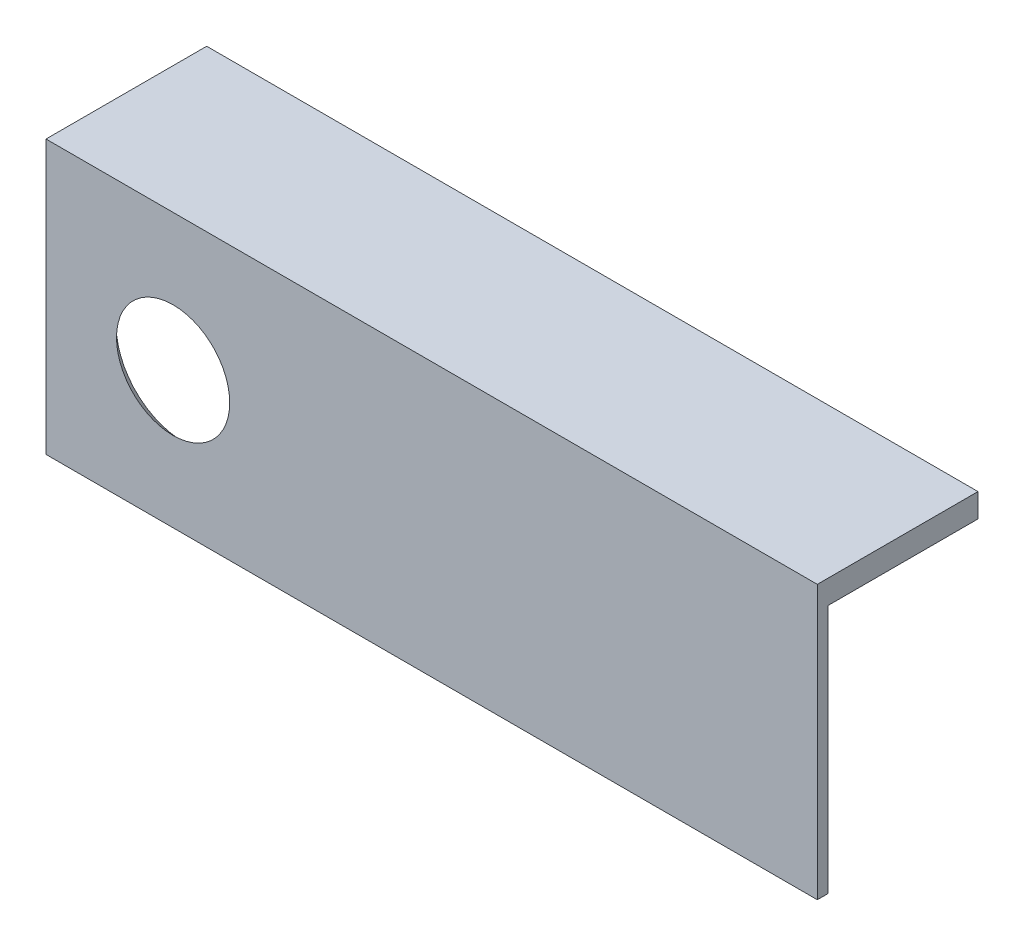
from build123d import *

# Parameters (mm, degrees)
CROQUIS1_W              = 48
CROQUIS1_H              = 17
SALIENTE_EXTRUIR1_DEPTH = 10
CROQUIS7_W              = 9.346110156
CROQUIS7_H              = 15.524186193
CORTAR_EXTRUIR1_DEPTH   = 49


with BuildPart() as part:
    # Croquis1 → Saliente-Extruir1 (new body)
    with BuildSketch(Plane.XY):
        Rectangle(CROQUIS1_W, CROQUIS1_H)
    extrude(amount=SALIENTE_EXTRUIR1_DEPTH)

    # Croquis7 → Cortar-Extruir1 (cut, through all)
    with BuildSketch(Plane.ZY.offset(24)):
        with Locations((4.673055078, -0.737906903)):
            Rectangle(CROQUIS7_W, CROQUIS7_H)
    extrude(amount=-CORTAR_EXTRUIR1_DEPTH, mode=Mode.SUBTRACT)

    # Croquis10 → Taladro de margen para M3.51 (revolve, cut)
    with BuildSketch(Plane(origin=(-16.090280194, 0, 9.346110156), x_dir=(0, 1, 0), z_dir=(1, 0, 0))):
        Polygon((0, 0), (0, 0.653889844), (1.95, 0.653889844), (1.95, 2.172799743), (4.2, 0), align=None)
    revolve(axis=Axis((-16.090280194, 0, 2.996110156), (0, 0, 1)), mode=Mode.SUBTRACT)


solid = part.part
